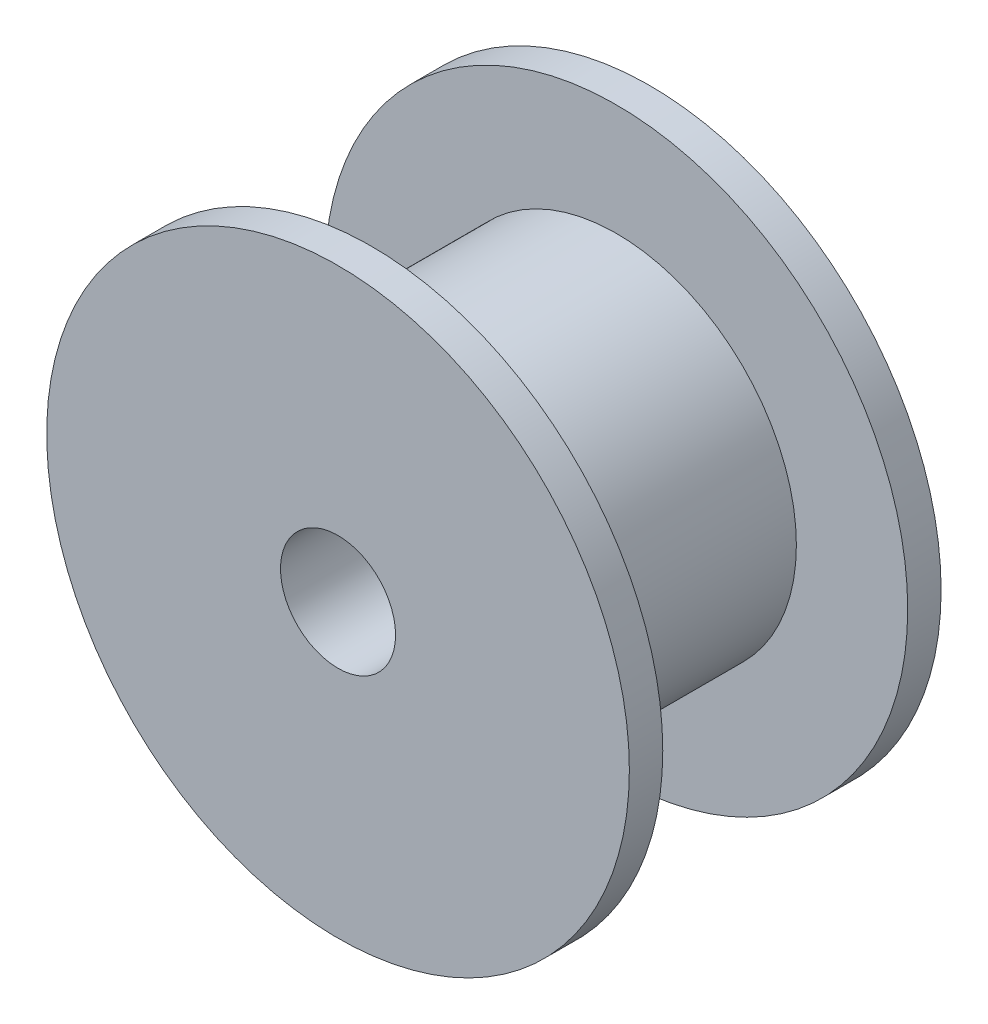
from build123d import *

# Parameters (mm, degrees)
SKETCH1_R           = 4.85
SKETCH1_R_2         = 1.55
BOSS_EXTRUDE1_DEPTH = 4.2
BOSS_EXTRUDE2_START = 4.2
SKETCH1_3_R         = 7.85
SKETCH1_3_R_2       = 4.85
BOSS_EXTRUDE2_DEPTH = 0.9
BOSS_EXTRUDE3_START = -4.2
SKETCH1_4_R         = 7.85
SKETCH1_4_R_2       = 4.85
BOSS_EXTRUDE3_DEPTH = 0.9


with BuildPart() as part:
    # Sketch1 → Boss-Extrude1 (new body, symmetric)
    with BuildSketch(Plane.XY):
        Circle(SKETCH1_R)
        Circle(SKETCH1_R_2, mode=Mode.SUBTRACT)
    extrude(amount=BOSS_EXTRUDE1_DEPTH, both=True)

    # Sketch1_3 → Boss-Extrude2 (add)
    with BuildSketch(Plane.XY.offset(BOSS_EXTRUDE2_START)):
        Circle(SKETCH1_3_R)
        Circle(SKETCH1_3_R_2, mode=Mode.SUBTRACT)
    extrude(amount=-BOSS_EXTRUDE2_DEPTH)

    # Sketch1_4 → Boss-Extrude3 (add)
    with BuildSketch(Plane.XY.offset(BOSS_EXTRUDE3_START)):
        Circle(SKETCH1_4_R)
        Circle(SKETCH1_4_R_2, mode=Mode.SUBTRACT)
    extrude(amount=BOSS_EXTRUDE3_DEPTH)


solid = part.part
